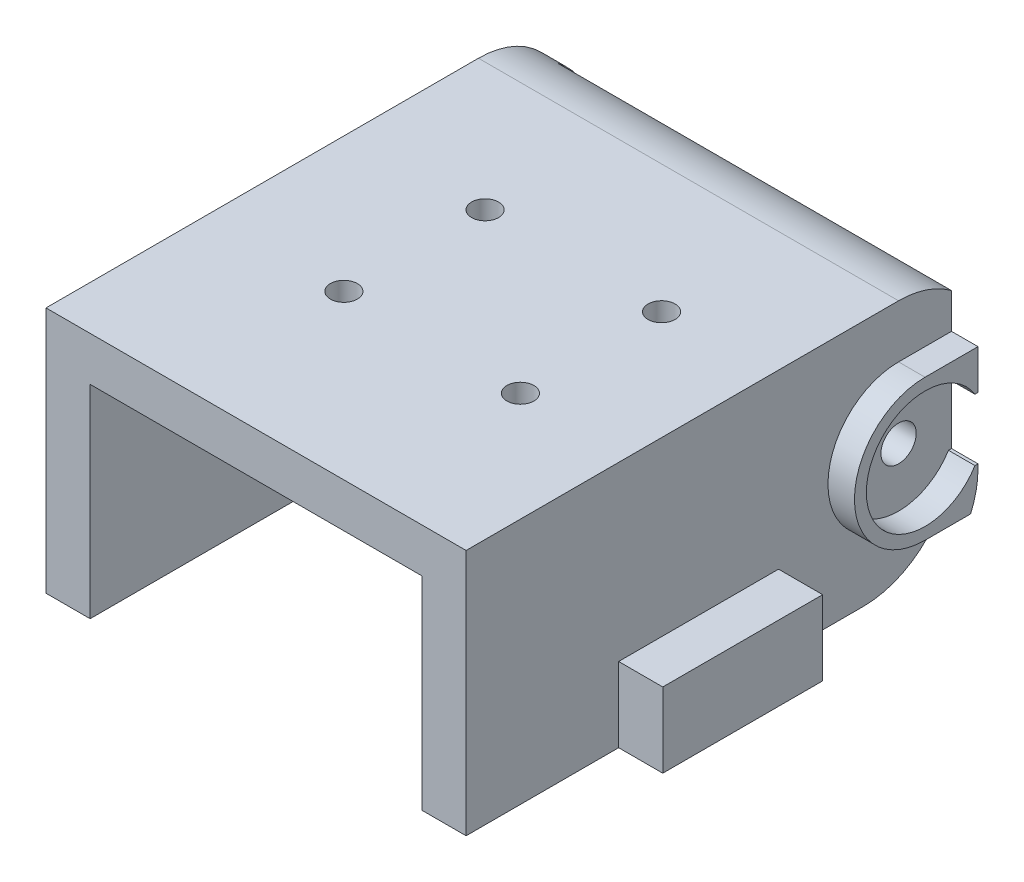
from build123d import *

# Parameters (mm, degrees)
SKETCH1_W           = 47.6
SKETCH1_H           = 28
BOSS_EXTRUDE1_DEPTH = 55
SKETCH3_R           = 2
CUT_EXTRUDE1_DEPTH  = 3
SKETCH4_W           = 18.116069914
SKETCH4_H           = 8.463303816
BOSS_EXTRUDE2_DEPTH = 5
BOSS_EXTRUDE4_DEPTH = 3
BOSS_EXTRUDE5_DEPTH = 3
SKETCH8_W           = 3
SKETCH8_H           = 28
BOSS_EXTRUDE7_DEPTH = 4
FILLET1_R           = 10
FILLET2_R           = 10
SKETCH9_R           = 1.530150167
CUT_EXTRUDE2_DEPTH  = 69.106093707
SKETCH10_W          = 37.6
SKETCH10_H          = 23
CUT_EXTRUDE4_DEPTH  = 40


with BuildPart() as part:
    # Sketch1 → Boss-Extrude1 (new body)
    with BuildSketch(Plane.XY):
        Rectangle(SKETCH1_W, SKETCH1_H)
    extrude(amount=BOSS_EXTRUDE1_DEPTH)

    # Sketch3 → Cut-Extrude1 (cut)
    with BuildSketch(Plane(origin=(23.8, 0, 0), x_dir=(0, 0, -1), z_dir=(1, 0, 0))):
        with Locations(Location((-6, 0, 0), (0, 0, 90))):
            Circle(SKETCH3_R)
    extrude(amount=-CUT_EXTRUDE1_DEPTH, mode=Mode.SUBTRACT)

    # Sketch4 → Boss-Extrude2 (add)
    with BuildSketch(Plane(origin=(23.8, 0, 0), x_dir=(0, 0, -1), z_dir=(1, 0, 0))):
        with Locations((-28.659392832, -9.768348092)):
            Rectangle(SKETCH4_W, SKETCH4_H)
    extrude(amount=BOSS_EXTRUDE2_DEPTH)

    # Sketch5 → Boss-Extrude4 (add)
    with BuildSketch(Plane(origin=(23.8, 0, 0), x_dir=(0, 0, -1), z_dir=(1, 0, 0))):
        with BuildLine():
            Line((-0.345576953, 3.5), (0, 3.5))
            Line((0, 3.5), (0, 8))
            Line((0, 8), (-6, 8))
            ThreePointArc((-6, 8), (-14, 0), (-6, -8))
            Line((-6, -8), (0, -8))
            Line((0, -8), (0, -3.5))
            Line((0, -3.5), (-0.345576953, -3.5))
            ThreePointArc((-0.345576953, -3.5), (-12.65, 0), (-0.345576953, 3.5))
        make_face()
    extrude(amount=BOSS_EXTRUDE4_DEPTH)

    # Sketch6 → Boss-Extrude5 (add)
    with BuildSketch(Plane.ZY.offset(23.8)):
        with BuildLine():
            Line((0, 8), (0, 5.291502622))
            ThreePointArc((0, 5.291502622), (8.828427125, 7.483314774), (14, 0))
            ThreePointArc((14, 0), (8.828427125, -7.483314774), (0, -5.291502622))
            Line((0, -5.291502622), (0, -8))
            ThreePointArc((0, -8), (10.472135955, -8.94427191), (16, 0))
            ThreePointArc((16, 0), (10.472135955, 8.94427191), (0, 8))
        make_face()
        with BuildLine():
            ThreePointArc((0, -5.291502622), (-0.657410327, -4.436089239), (-1.193747285, -3.5))
            Line((-1.193747285, -3.5), (-3.367496998, -3.5))
            ThreePointArc((-3.367496998, -3.5), (-2.006403125, -5.991452996), (0, -8))
            Line((0, -8), (0, -5.291502622))
        make_face()
        with BuildLine():
            Line((-3.367496998, 3.5), (-1.193747285, 3.5))
            ThreePointArc((-1.193747285, 3.5), (-0.657410327, 4.436089239), (0, 5.291502622))
            Line((0, 5.291502622), (0, 8))
            ThreePointArc((0, 8), (-2.006403125, 5.991452996), (-3.367496998, 3.5))
        make_face()
    extrude(amount=BOSS_EXTRUDE5_DEPTH)

    # Sketch8 → Boss-Extrude7 (add)
    with BuildSketch(Plane(origin=(0, 0, 0), x_dir=(-1, 0, 0), z_dir=(0, 0, -1))):
        with Locations((22.3, 0)):
            Rectangle(SKETCH8_W, SKETCH8_H)
    extrude(amount=BOSS_EXTRUDE7_DEPTH)

    # Fillet1
    fillet1_edges = [part.edges().sort_by_distance(p)[0] for p in [
        (-22.3, 14, -4),
        (1.5, -14, 0),
    ]]
    fillet(fillet1_edges, radius=FILLET1_R)

    # Fillet2
    fillet2_edges = [part.edges().sort_by_distance(p)[0] for p in [
        (-22.3, -14, -4),
    ]]
    fillet(fillet2_edges, radius=FILLET2_R)

    # Sketch9 → Cut-Extrude2 (cut, through all)
    with BuildSketch(Plane(origin=(0, 14, 0), x_dir=(1, 0, 0), z_dir=(0, 1, 0))):
        with Locations(Location((-8.55, -20.5, 0), (0, 0, 270))):
            Circle(SKETCH9_R)
        with Locations(Location((11.45, -20.5, 0), (0, 0, 270))):
            Circle(SKETCH9_R)
        with Locations(Location((11.45, -36.5, 0), (0, 0, 270))):
            Circle(SKETCH9_R)
        with Locations(Location((-8.55, -36.5, 0), (0, 0, 270))):
            Circle(SKETCH9_R)
    extrude(amount=-CUT_EXTRUDE2_DEPTH, mode=Mode.SUBTRACT)

    # Sketch10 → Cut-Extrude4 (cut)
    with BuildSketch(Plane.XY.offset(55)):
        with Locations((0, -2.5)):
            Rectangle(SKETCH10_W, SKETCH10_H)
    extrude(amount=-CUT_EXTRUDE4_DEPTH, mode=Mode.SUBTRACT)


solid = part.part
